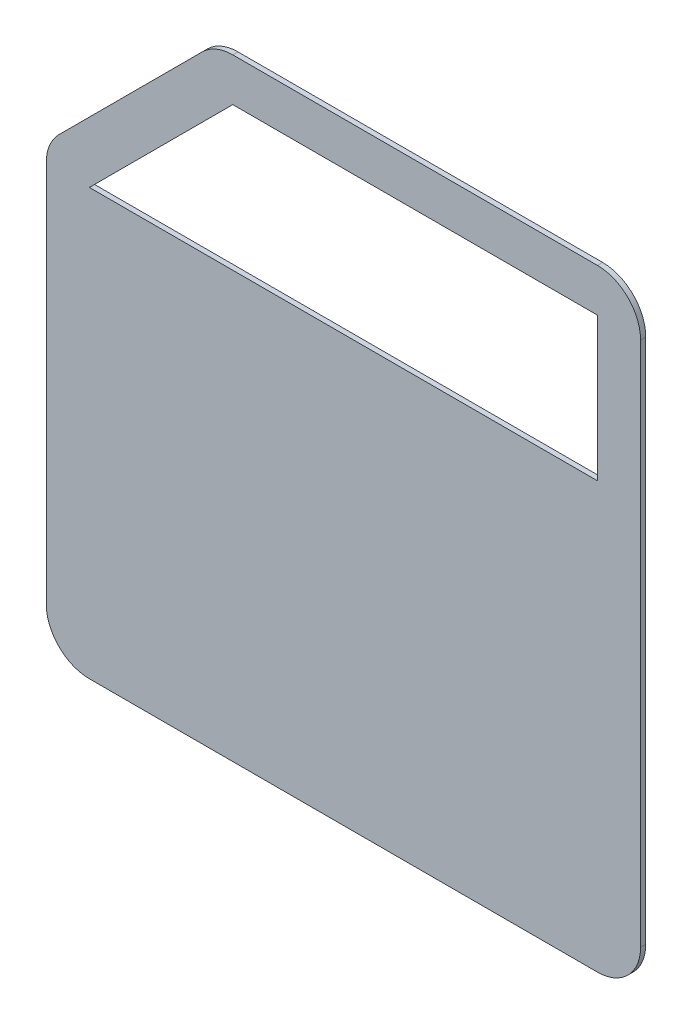
from build123d import *

# Parameters (mm, degrees)
BOSS_EXTRUDE1_DEPTH = 3


with BuildPart() as part:
    # Sketch1 → Boss-Extrude1 (new body)
    with BuildSketch(Plane.XY):
        with BuildLine():
            Line((711.17673453, 385), (499.657382069, 385))
            ThreePointArc((499.657382069, 385), (490.09029626, 383.096988313), (481.979712539, 377.67766953))
            Line((481.979712539, 377.67766953), (398.788878519, 294.486835509))
            ThreePointArc((398.788878519, 294.486835509), (393.369559736, 286.376251789), (391.466548048, 276.80916598))
            Line((391.466548048, 276.80916598), (391.466548048, 55))
            ThreePointArc((391.466548048, 55), (398.788878519, 37.32233047), (416.466548048, 30))
            Line((416.466548048, 30), (711.17673453, 30))
            ThreePointArc((711.17673453, 30), (728.85440406, 37.32233047), (736.17673453, 55))
            Line((736.17673453, 55), (736.17673453, 360))
            ThreePointArc((736.17673453, 360), (728.85440406, 377.67766953), (711.17673453, 385))
        make_face()
        Polygon((416.466548048, 276.80916598), (499.657382069, 360), (711.17673453, 360), (711.17673453, 276.80916598), align=None, mode=Mode.SUBTRACT)
    extrude(amount=-BOSS_EXTRUDE1_DEPTH)


solid = part.part
